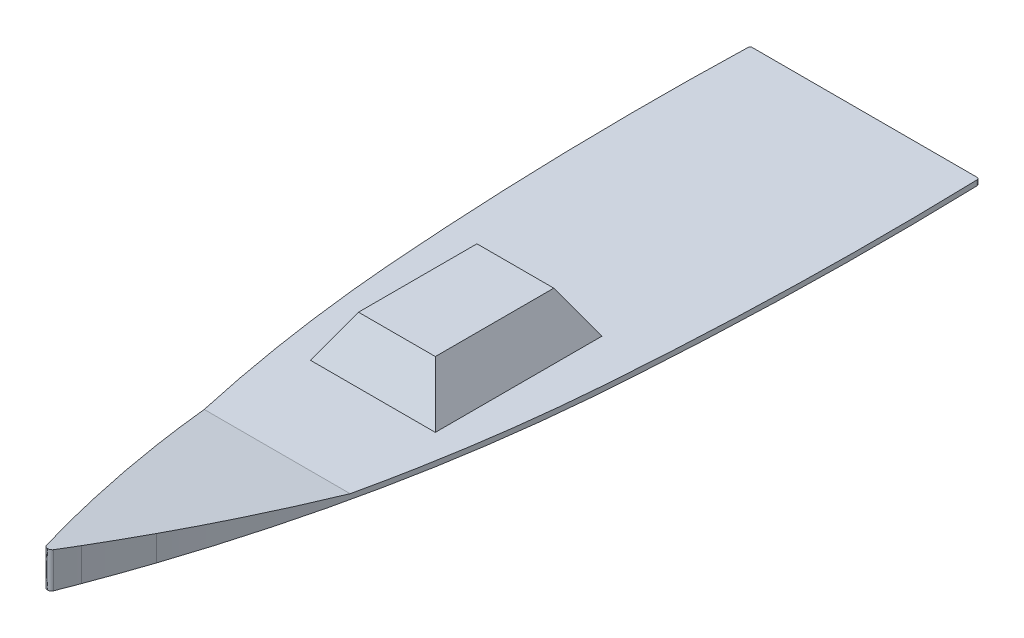
from build123d import *

# Parameters (mm, degrees)
BOSS_EXTRUDE1_DEPTH     = 12.7
SKETCH2_W               = 304.8
SKETCH2_H               = 406.4
BOSS_EXTRUDE2_DEPTH     = 101.6
BOSS_EXTRUDE2_TAPER     = 30
BOSS_EXTRUDE3_DEPTH     = 74.997994
SKETCH7_W               = 508
SKETCH7_H               = 565.262345734
CUT_EXTRUDE_THIN1_DEPTH = 88.9


with BuildPart() as part:
    # Sketch1 → Boss-Extrude1 (new body)
    with BuildSketch(Plane(origin=(0, 0, 0), x_dir=(1, 0, 0), z_dir=(0, 1, 0))):
        with BuildLine():
            Line((282.178632733, 648.295571298), (-266.742186919, 648.295571298))
            add(Edge.make_bspline(
                [(-266.742186919, 648.295571298), (-267.071605745, 648.295571298), (-267.395635709, 648.263919559), (-267.873929001, 648.170912239), (-268.032058898, 648.132267139), (-268.345661652, 648.039370684), (-268.50177233, 647.984795184), (-268.956632468, 647.800648785), (-269.244615581, 647.650355056), (-269.790494311, 647.295478174), (-270.050162442, 647.088526762), (-270.517954254, 646.635397593), (-270.728625138, 646.388172726), (-271.009326112, 645.985928841), (-271.097290935, 645.845887253), (-271.257701503, 645.560682787), (-271.330552726, 645.415064516), (-271.527511364, 644.969353179), (-271.630228502, 644.660487559), (-271.776102581, 644.018329571), (-271.817451265, 643.692751749), (-271.827054921, 643.363460144)],
                knots=[0, 0, 0, 0, 0.125, 0.125, 0.1875, 0.1875, 0.25, 0.25, 0.375, 0.375, 0.5, 0.5, 0.625, 0.625, 0.6875, 0.6875, 0.75, 0.75, 0.875, 0.875, 1, 1, 1, 1], degree=3))
            add(Edge.make_bspline(
                [(-271.827054921, 643.363460144), (-275.619083406, 513.341805118), (-276.544805746, 362.627319415), (-273.085954654, 195.044872043), (-271.031571931, 119.847777975), (-268.671598158, 56.063015866), (-263.132069886, -66.069662637), (-257.433335824, -160.037587725), (-250.764013725, -248.746196584), (-248.487290338, -276.985560905), (-240.18277645, -371.092813978), (-227.549965864, -472.778666072), (-212.610504693, -566.462025361), (-203.222738687, -622.637020096), (-193.844144823, -673.237560968), (-182.290724358, -729.93756534), (-174.271233518, -767.830757671), (-162.896711093, -818.371776774), (-149.252675491, -874.959703685), (-120.211836445, -987.796815407), (-92.347727316, -1081.139961257), (-67.767522398, -1155.104428702)],
                knots=[0.00273139, 0.00273139, 0.00273139, 0.00273139, 0.21875, 0.253283969, 0.28125, 0.34375, 0.359375, 0.484375, 0.5, 0.506595501, 0.53125, 0.65625, 0.67558323, 0.6875, 0.75, 0.760136029, 0.78125, 0.8125, 0.84375, 0.875, 1, 1, 1, 1], degree=3))
            add(Edge.make_bspline(
                [(-67.767522398, -1155.104428702), (-52.556679091, -1200.875484247), (-36.785485559, -1245.497662336), (-19.856460022, -1290.661446214)],
                knots=[0, 0, 0, 0, 1, 1, 1, 1], degree=3))
            ThreePointArc((-19.856460022, -1290.661446214), (-10.585699255, -1315.137822671), (-1.146808464, -1339.549855571))
            add(Edge.make_bspline(
                [(-1.146808464, -1339.549855571), (-0.800991585, -1340.435186307), (0.157660597, -1342.101440742), (2.269639684, -1344.064855704), (4.866902728, -1345.317723875), (6.767749431, -1345.604428702), (7.718222907, -1345.604428702)],
                knots=[0.808269867, 0.808269867, 0.808269867, 0.808269867, 0.8562024, 0.904134933, 0.952067467, 0.99999997, 0.99999997, 0.99999997, 0.99999997], degree=3))
            add(Edge.make_bspline(
                [(16.583254278, -1339.549855571), (16.237437398, -1340.435186307), (15.278785216, -1342.101440742), (13.16680613, -1344.064855704), (10.569543086, -1345.317723875), (8.668696382, -1345.604428702), (7.718222907, -1345.604428702)],
                knots=[0.808269867, 0.808269867, 0.808269867, 0.808269867, 0.8562024, 0.904134933, 0.952067467, 1, 1, 1, 1], degree=3))
            ThreePointArc((16.583254278, -1339.549855571), (26.022145069, -1315.137822671), (35.292905835, -1290.661446214))
            add(Edge.make_bspline(
                [(83.203968212, -1155.104428702), (67.993124905, -1200.875484247), (52.221931373, -1245.497662336), (35.292905835, -1290.661446214)],
                knots=[0, 0, 0, 0, 1, 1, 1, 1], degree=3))
            add(Edge.make_bspline(
                [(287.263500734, 643.363460144), (291.055529219, 513.341805118), (291.98125156, 362.627319415), (288.522400468, 195.044872043), (286.468017744, 119.847777975), (284.108043971, 56.063015866), (278.568515699, -66.069662637), (272.869781637, -160.037587725), (266.200459538, -248.746196584), (263.923736151, -276.985560905), (255.619222264, -371.092813978), (242.986411678, -472.778666072), (228.046950506, -566.462025361), (218.659184501, -622.637020096), (209.280590637, -673.237560968), (197.727170171, -729.93756534), (189.707679331, -767.830757671), (178.333156907, -818.371776774), (164.689121304, -874.959703685), (135.648282259, -987.796815407), (107.78417313, -1081.139961257), (83.203968212, -1155.104428702)],
                knots=[0.00273139, 0.00273139, 0.00273139, 0.00273139, 0.21875, 0.253283969, 0.28125, 0.34375, 0.359375, 0.484375, 0.5, 0.506595501, 0.53125, 0.65625, 0.67558323, 0.6875, 0.75, 0.760136029, 0.78125, 0.8125, 0.84375, 0.875, 1, 1, 1, 1], degree=3))
            add(Edge.make_bspline(
                [(287.263500734, 643.363460144), (287.253897353, 643.692742337), (287.212682478, 644.015685877), (287.105404307, 644.490986496), (287.062014477, 644.64789), (286.959654545, 644.958572893), (286.900349557, 645.112951735), (286.70240916, 645.561902127), (286.54331042, 645.845111412), (286.171615525, 646.379810232), (285.956670805, 646.632890984), (285.489257001, 647.086264872), (285.235568792, 647.289160564), (284.824662826, 647.557338937), (284.681966904, 647.640918903), (284.392063507, 647.792397056), (284.244309066, 647.860727323), (283.491814956, 648.166105966), (282.837451466, 648.295571298), (282.178632733, 648.295571298)],
                knots=[0, 0, 0, 0, 0.125, 0.125, 0.1875, 0.1875, 0.25, 0.25, 0.375, 0.375, 0.5, 0.5, 0.625, 0.625, 0.6875, 0.6875, 0.75, 0.75, 1, 1, 1, 1], degree=3))
        make_face()
    extrude(amount=BOSS_EXTRUDE1_DEPTH)

    # Sketch2 → Boss-Extrude2 (add)
    with BuildSketch(Plane(origin=(0, 12.7, 0), x_dir=(1, 0, 0), z_dir=(0, 1, 0))):
        with Locations((7.718222907, -348.654428702)):
            Rectangle(SKETCH2_W, SKETCH2_H)
    extrude(amount=BOSS_EXTRUDE2_DEPTH, taper=BOSS_EXTRUDE2_TAPER)

    # Sketch4 → Boss-Extrude3 (add)
    with BuildSketch(Plane(origin=(0, 12.7, 0), x_dir=(1, 0, 0), z_dir=(0, 1, 0))):
        with BuildLine():
            Line((-170.289770142, -785.339473227), (185.726215956, -785.339473227))
            add(Edge.make_bspline(
                [(83.203968212, -1155.104428702), (107.78417313, -1081.139961257), (135.648282259, -987.796815407), (164.689121304, -874.959703685), (176.435611281, -826.241748411), (183.262218235, -796.353082345), (185.726215956, -785.339473227)],
                knots=[0.00273139, 0.00273139, 0.00273139, 0.00273139, 0.12773139, 0.15898139, 0.19023139, 0.208443099, 0.208443099, 0.208443099, 0.208443099], degree=3))
            add(Edge.make_bspline(
                [(35.292905835, -1290.661446214), (52.221931373, -1245.497662336), (67.993124905, -1200.875484247), (83.203968212, -1155.104428702)],
                knots=[0, 0, 0, 0, 1, 1, 1, 1], degree=3))
            ThreePointArc((35.292905835, -1290.661446214), (26.022145069, -1315.137822671), (16.583254278, -1339.549855571))
            add(Edge.make_bspline(
                [(7.718222907, -1345.604428702), (8.668696382, -1345.604428702), (10.569543086, -1345.317723875), (13.16680613, -1344.064855704), (15.278785216, -1342.101440742), (16.237437398, -1340.435186307), (16.583254278, -1339.549855571)],
                knots=[0.808269867, 0.808269867, 0.808269867, 0.808269867, 0.8562024, 0.904134933, 0.952067467, 1, 1, 1, 1], degree=3))
            add(Edge.make_bspline(
                [(-1.146808464, -1339.549855571), (-0.800991585, -1340.435186307), (0.157660597, -1342.101440742), (2.269639684, -1344.064855704), (4.866902728, -1345.317723875), (6.767749431, -1345.604428702), (7.718222907, -1345.604428702)],
                knots=[0.808269867, 0.808269867, 0.808269867, 0.808269867, 0.8562024, 0.904134933, 0.952067467, 0.99999997, 0.99999997, 0.99999997, 0.99999997], degree=3))
            ThreePointArc((-1.146808464, -1339.549855571), (-10.585699255, -1315.137822671), (-19.856460022, -1290.661446214))
            add(Edge.make_bspline(
                [(-67.767522398, -1155.104428702), (-52.556679091, -1200.875484247), (-36.785485559, -1245.497662336), (-19.856460022, -1290.661446214)],
                knots=[0, 0, 0, 0, 1, 1, 1, 1], degree=3))
            add(Edge.make_bspline(
                [(-170.289770142, -785.339473227), (-167.825772422, -796.353082345), (-160.999165467, -826.241748411), (-149.252675491, -874.959703685), (-120.211836445, -987.796815407), (-92.347727316, -1081.139961257), (-67.767522398, -1155.104428702)],
                knots=[0.794288291, 0.794288291, 0.794288291, 0.794288291, 0.8125, 0.84375, 0.875, 1, 1, 1, 1], degree=3))
        make_face()
    extrude(amount=BOSS_EXTRUDE3_DEPTH)

    # Sketch7 → Cut-Extrude-Thin1 (cut)
    with BuildSketch(Plane(origin=(0, -90.799805475, 12.154612278), x_dir=(1, 0, 0), z_dir=(0, 0.991159167, -0.132678207))):
        with Locations((7.718222907, -1062.71260383)):
            Rectangle(SKETCH7_W, SKETCH7_H)
    extrude(amount=CUT_EXTRUDE_THIN1_DEPTH, mode=Mode.SUBTRACT)


solid = part.part
